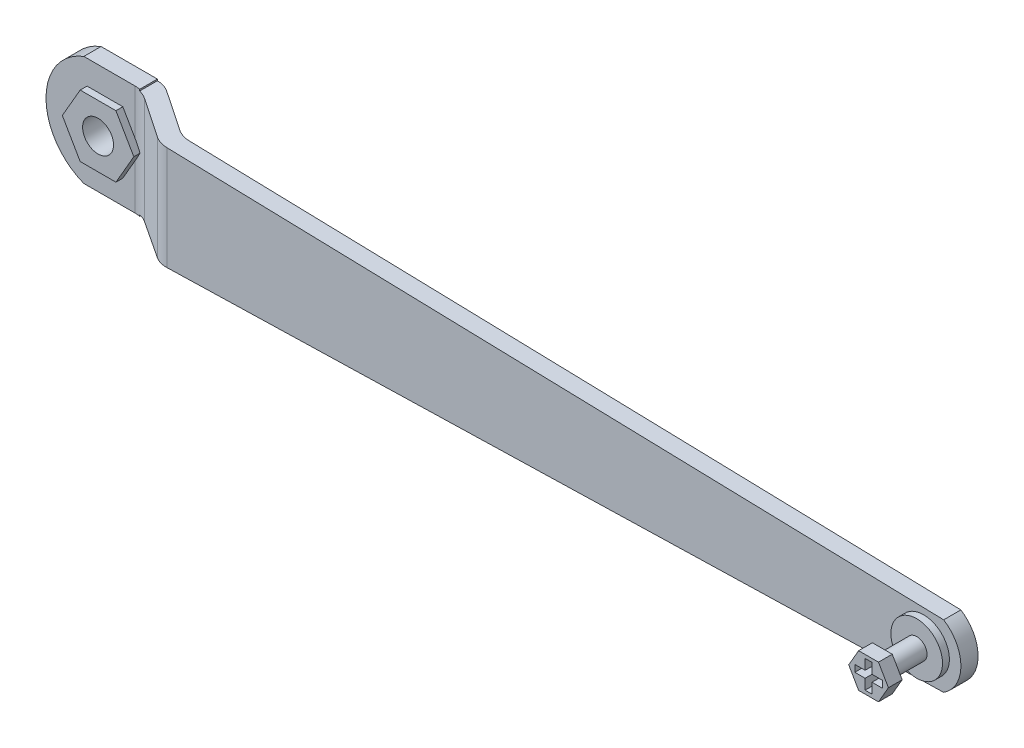
from build123d import *

# Parameters (mm, degrees)
BOSS_EXTRUDE1_DEPTH = 32
FILLET1_R           = 7
CUT_EXTRUDE1_DEPTH  = 32
CUT_EXTRUDE2_DEPTH  = 32
CUT_EXTRUDE3_DEPTH  = 32
SKETCH7_R           = 3
BOSS_EXTRUDE2_DEPTH = 12
BOSS_EXTRUDE3_DEPTH = 4
SKETCH9_W           = 3
SKETCH9_H           = 2
SKETCH9_W_2         = 2
SKETCH9_H_2         = 3
CUT_EXTRUDE4_DEPTH  = 4
SKETCH10_R          = 7.5
BOSS_EXTRUDE4_DEPTH = 2
BOSS_EXTRUDE5_DEPTH = 2
BOSS_EXTRUDE6_DEPTH = 9
SKETCH17_R          = 4.5
CUT_EXTRUDE5_DEPTH  = 10


with BuildPart() as part:
    # Sketch1 → Boss-Extrude1 (new body)
    with BuildSketch(Plane(origin=(0, 0, 0), x_dir=(1, 0, 0), z_dir=(0, 1, 0))):
        Polygon((0, 0), (28, 0), (43, -10), (276, -10), (276, -5), (44.513878189, -5), (29.513878189, 5), (0, 5), align=None)
    extrude(amount=BOSS_EXTRUDE1_DEPTH)

    # Fillet1
    fillet1_edges = [part.edges().sort_by_distance(p)[0] for p in [
        (29.513878189, 16, -5),
        (44.513878189, 16, 5),
        (43, 16, 10),
        (28, 16, 0),
    ]]
    fillet(fillet1_edges, radius=FILLET1_R)

    # Sketch4 → Cut-Extrude1 (cut)
    with BuildSketch(Plane(origin=(0, 0, -5), x_dir=(-1, 0, 0), z_dir=(0, 0, -1))):
        with BuildLine():
            Line((-11, 32), (12.683379318, 39.348401976))
            Line((12.683379318, 39.348401976), (11.560507562, -17.356621714))
            Line((11.560507562, -17.356621714), (-11, 0))
            ThreePointArc((-11, 0), (0, 16), (-11, 32))
        make_face()
    extrude(amount=-CUT_EXTRUDE1_DEPTH, mode=Mode.SUBTRACT)

    # Sketch5 → Cut-Extrude2 (cut)
    with BuildSketch(Plane(origin=(0, 0, -5), x_dir=(-1, 0, 0), z_dir=(0, 0, -1))):
        Polygon((-276, 25), (-27.394448725, 31.56693909), (-27.394448725, 32), (-276, 32), align=None)
        Polygon((-27.394448725, 0), (-27.394448725, 0.43306091), (-276, 7), (-276, 0), align=None)
    extrude(amount=-CUT_EXTRUDE2_DEPTH, mode=Mode.SUBTRACT)

    # Sketch6 → Cut-Extrude3 (cut)
    with BuildSketch(Plane(origin=(0, 0, 5), x_dir=(-1, 0, 0), z_dir=(0, 0, -1))):
        with BuildLine():
            ThreePointArc((-276, 16.000000308), (-274.6681814, 21.205641364), (-271, 25.132075472))
            Line((-271, 25.132075472), (-276, 25))
            Line((-276, 25), (-276, 16.000000308))
        make_face()
        with BuildLine():
            ThreePointArc((-271, 6.867924528), (-274.668181548, 10.794358906), (-276, 16.000000308))
            Line((-276, 16.000000308), (-276, 7))
            Line((-276, 7), (-271, 6.867924528))
        make_face()
    extrude(amount=-CUT_EXTRUDE3_DEPTH, mode=Mode.SUBTRACT)

    # Sketch7 → Boss-Extrude2 (add)
    with BuildSketch(Plane.XY.offset(10)):
        with Locations((265.160519758, 16)):
            Circle(SKETCH7_R)
    extrude(amount=BOSS_EXTRUDE2_DEPTH)

    # Sketch8 → Boss-Extrude3 (add)
    with BuildSketch(Plane.XY.offset(22)):
        Polygon((270.93402245, 16), (268.047271104, 21), (262.273768412, 21), (259.387017066, 16), (262.273768412, 11), (268.047271104, 11), align=None)
    extrude(amount=BOSS_EXTRUDE3_DEPTH)

    # Sketch9 → Cut-Extrude4 (cut)
    with BuildSketch(Plane.XY.offset(26)):
        with Locations((267.660519758, 16)):
            Rectangle(SKETCH9_W, SKETCH9_H)
        with Locations((265.160519758, 18.5)):
            Rectangle(SKETCH9_W_2, SKETCH9_H_2)
        with Locations((265.160519758, 16)):
            Rectangle(SKETCH9_W_2, SKETCH9_H)
        with Locations((262.660519758, 16)):
            Rectangle(SKETCH9_W, SKETCH9_H)
        with Locations((265.160519758, 13.5)):
            Rectangle(SKETCH9_W_2, SKETCH9_H_2)
    extrude(amount=-CUT_EXTRUDE4_DEPTH, mode=Mode.SUBTRACT)

    # Sketch10 → Boss-Extrude4 (add)
    with BuildSketch(Plane.XY.offset(10)):
        with Locations((265.160519758, 16)):
            Circle(SKETCH10_R)
    extrude(amount=BOSS_EXTRUDE4_DEPTH)

    # Sketch11 → Boss-Extrude5 (add)
    with BuildSketch(Plane.XY):
        Polygon((27.528668482, 16), (22.332516059, 25), (11.940211214, 25), (6.744058791, 16), (11.940211214, 7), (22.332516059, 7), align=None)
    extrude(amount=BOSS_EXTRUDE5_DEPTH)

    # Sketch12 → Boss-Extrude6 (add)
    with BuildSketch(Plane.XY.offset(2)):
        Polygon((22.332516059, 7), (27.528668482, 16), (22.332516059, 25), (11.940211214, 25), (6.744058791, 16), (11.940211214, 7), align=None)
    extrude(amount=-BOSS_EXTRUDE6_DEPTH)

    # Sketch17 → Cut-Extrude5 (cut)
    with BuildSketch(Plane.XY.offset(2)):
        with Locations((17.136363636, 16)):
            Circle(SKETCH17_R)
    extrude(amount=-CUT_EXTRUDE5_DEPTH, mode=Mode.SUBTRACT)


solid = part.part
